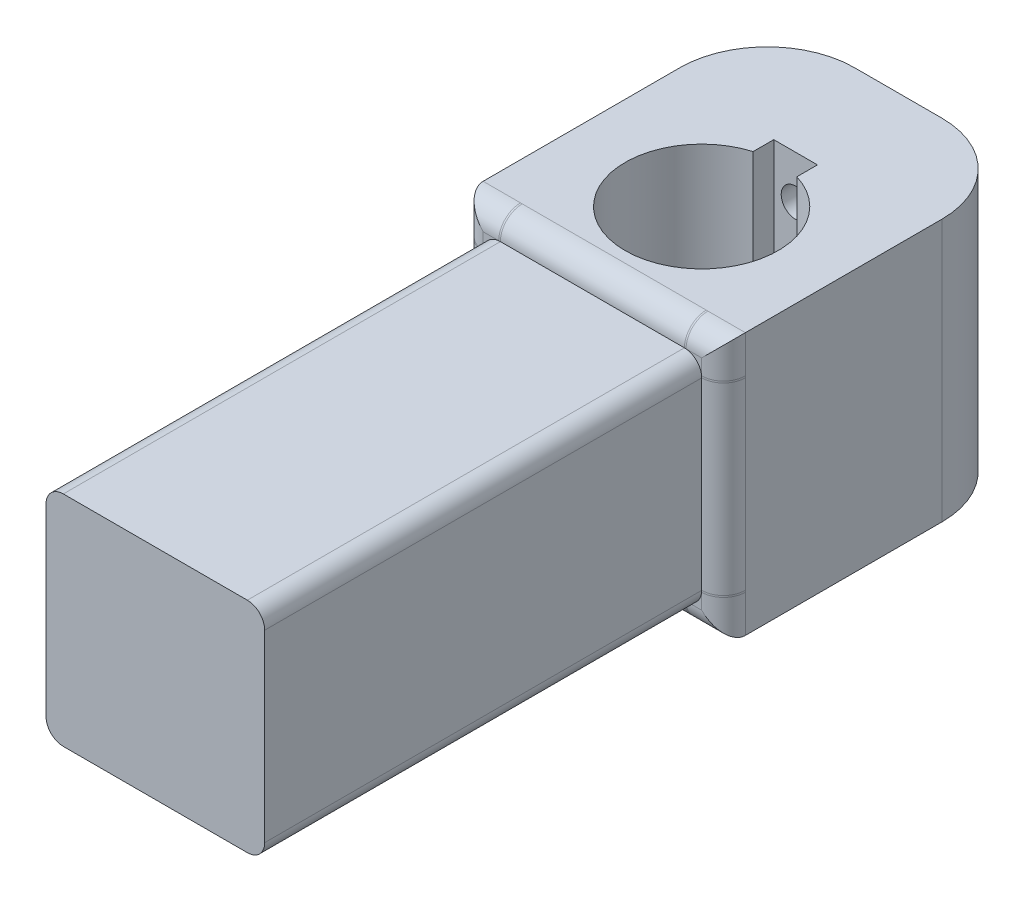
from build123d import *

# Parameters (mm, degrees)
BOSS_EXTRUDE1_DEPTH       = 100
SKETCH2_W                 = 60
SKETCH2_H                 = 60
BOSS_EXTRUDE2_DEPTH       = 70
CUT_EXTRUDE2_DEPTH        = 60
CUT_EXTRUDE3_DEPTH        = 60
M6_CLEARANCE_HOLE1_REACH  = 177.214
M6_CLEARANCE_HOLE1_BORE_R = 3.3
FILLET1_R                 = 20
FILLET2_R                 = 5


with BuildPart() as part:
    # Sketch1 → Boss-Extrude1 (new body)
    with BuildSketch(Plane.XY):
        with BuildLine():
            Line((25.019, 21.05025), (25.019, -21.05025))
            ThreePointArc((25.019, -21.05025), (23.856580038, -23.856580038), (21.05025, -25.019))
            Line((21.05025, -25.019), (-21.05025, -25.019))
            ThreePointArc((-21.05025, -25.019), (-23.856580038, -23.856580038), (-25.019, -21.05025))
            Line((-25.019, -21.05025), (-25.019, 21.05025))
            ThreePointArc((-25.019, 21.05025), (-23.856580038, 23.856580038), (-21.05025, 25.019))
            Line((-21.05025, 25.019), (21.05025, 25.019))
            ThreePointArc((21.05025, 25.019), (23.856580038, 23.856580038), (25.019, 21.05025))
        make_face()
    extrude(amount=BOSS_EXTRUDE1_DEPTH)

    # Sketch2 → Boss-Extrude2 (add)
    with BuildSketch(Plane.XY):
        Rectangle(SKETCH2_W, SKETCH2_H)
    extrude(amount=-BOSS_EXTRUDE2_DEPTH)

    # Sketch3 → Cut-Extrude2 (cut)
    with BuildSketch(Plane.XZ.offset(30)):
        with BuildLine():
            ThreePointArc((17.5, -25), (-10.458250332, -10.9687848), (-5, -41.770509831))
            Line((-5, -41.770509831), (-5, -38.5))
            Line((-5, -38.5), (5, -38.5))
            Line((5, -38.5), (5, -41.770509831))
            ThreePointArc((5, -41.770509831), (14.0312152, -35.458250332), (17.5, -25))
        make_face()
        with BuildLine():
            Line((-5, -38.5), (-5, -41.770509831))
            ThreePointArc((-5, -41.770509831), (0, -42.5), (5, -41.770509831))
            Line((5, -41.770509831), (5, -38.5))
            Line((5, -38.5), (-5, -38.5))
        make_face()
    extrude(amount=-CUT_EXTRUDE2_DEPTH, mode=Mode.SUBTRACT)

    # Sketch3_7 → Cut-Extrude3 (cut)
    with BuildSketch(Plane.XZ.offset(30)):
        with BuildLine():
            Line((-5, -41.770509831), (-5, -46.5))
            Line((-5, -46.5), (5, -46.5))
            Line((5, -46.5), (5, -41.770509831))
            ThreePointArc((5, -41.770509831), (0, -42.5), (-5, -41.770509831))
        make_face()
    extrude(amount=-CUT_EXTRUDE3_DEPTH, mode=Mode.SUBTRACT)

    # M6 Clearance Hole1 bore → M6 Clearance Hole1 (cut, up to next)
    with BuildSketch(Plane(origin=(0, 0, -70), x_dir=(-1, 0, 0), z_dir=(0, 0, -1)), mode=Mode.PRIVATE) as m6_clearance_hole1_sk1:
        with Locations((0, 20)):
            Circle(M6_CLEARANCE_HOLE1_BORE_R)
    m6_clearance_hole1_tool1 = extrude(m6_clearance_hole1_sk1.sketch, amount=-M6_CLEARANCE_HOLE1_REACH, mode=Mode.PRIVATE) & part.part
    # M6 Clearance Hole1 bore → M6 Clearance Hole1 (cut, up to next)
    with BuildSketch(Plane(origin=(0, 0, -70), x_dir=(-1, 0, 0), z_dir=(0, 0, -1)), mode=Mode.PRIVATE) as m6_clearance_hole1_sk2:
        Circle(M6_CLEARANCE_HOLE1_BORE_R)
    m6_clearance_hole1_tool2 = extrude(m6_clearance_hole1_sk2.sketch, amount=-M6_CLEARANCE_HOLE1_REACH, mode=Mode.PRIVATE) & part.part
    # M6 Clearance Hole1 bore → M6 Clearance Hole1 (cut, up to next)
    with BuildSketch(Plane(origin=(0, 0, -70), x_dir=(-1, 0, 0), z_dir=(0, 0, -1)), mode=Mode.PRIVATE) as m6_clearance_hole1_sk3:
        with Locations((0, -20)):
            Circle(M6_CLEARANCE_HOLE1_BORE_R)
    m6_clearance_hole1_tool3 = extrude(m6_clearance_hole1_sk3.sketch, amount=-M6_CLEARANCE_HOLE1_REACH, mode=Mode.PRIVATE) & part.part
    add(m6_clearance_hole1_tool1.solids().sort_by_distance((0, 20, -70))[0], mode=Mode.SUBTRACT)
    add(m6_clearance_hole1_tool2.solids().sort_by_distance((0, 0, -70))[0], mode=Mode.SUBTRACT)
    add(m6_clearance_hole1_tool3.solids().sort_by_distance((0, -20, -70))[0], mode=Mode.SUBTRACT)

    # Fillet1
    fillet1_edges = [part.edges().sort_by_distance(p)[0] for p in [
        (-30, 0, -70),
        (30, 0, -70),
    ]]
    fillet(fillet1_edges, radius=FILLET1_R)

    # Fillet2
    fillet2_edges = [part.edges().sort_by_distance(p)[0] for p in [
        (-30, 0, 0),
        (0, -30, 0),
        (30, 0, 0),
        (0, 30, 0),
    ]]
    fillet(fillet2_edges, radius=FILLET2_R)


solid = part.part
